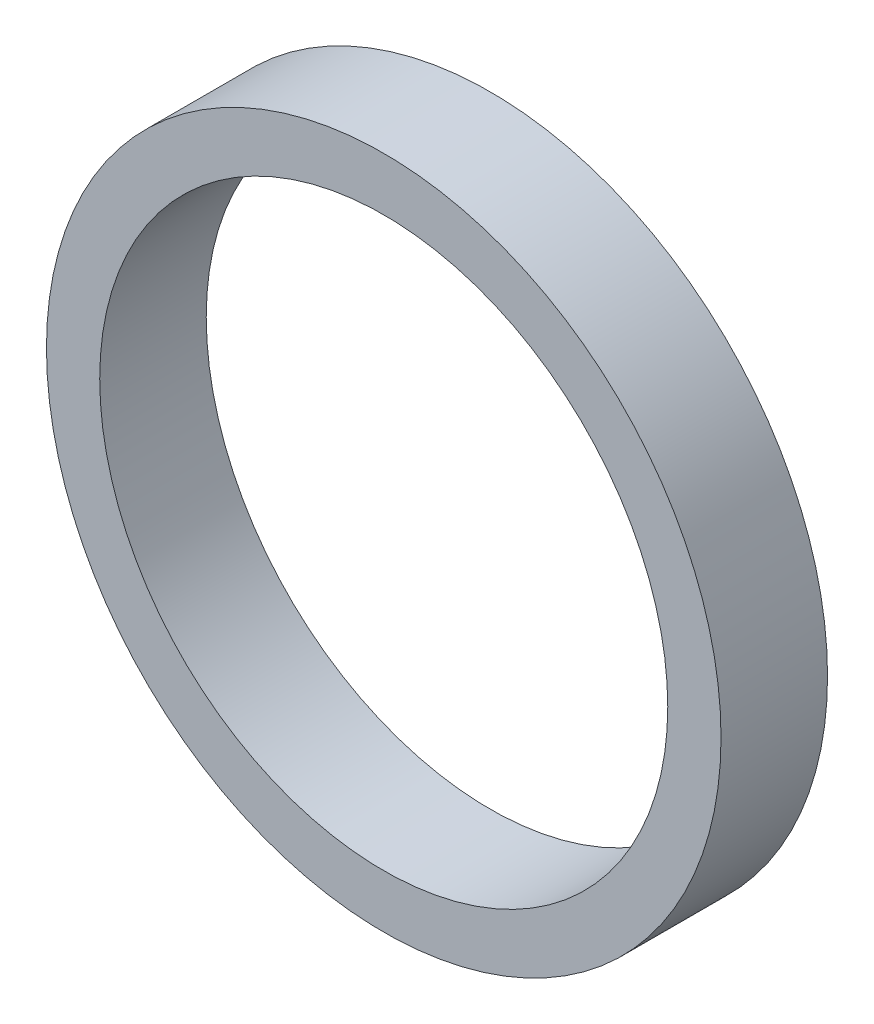
from build123d import *

# Parameters (mm, degrees)
SKETCH1_R           = 9.5
SKETCH1_R_2         = 8
BOSS_EXTRUDE1_DEPTH = 3


with BuildPart() as part:
    # Sketch1 → Boss-Extrude1 (new body)
    with BuildSketch(Plane.XY):
        Circle(SKETCH1_R)
        Circle(SKETCH1_R_2, mode=Mode.SUBTRACT)
    extrude(amount=BOSS_EXTRUDE1_DEPTH)


solid = part.part
